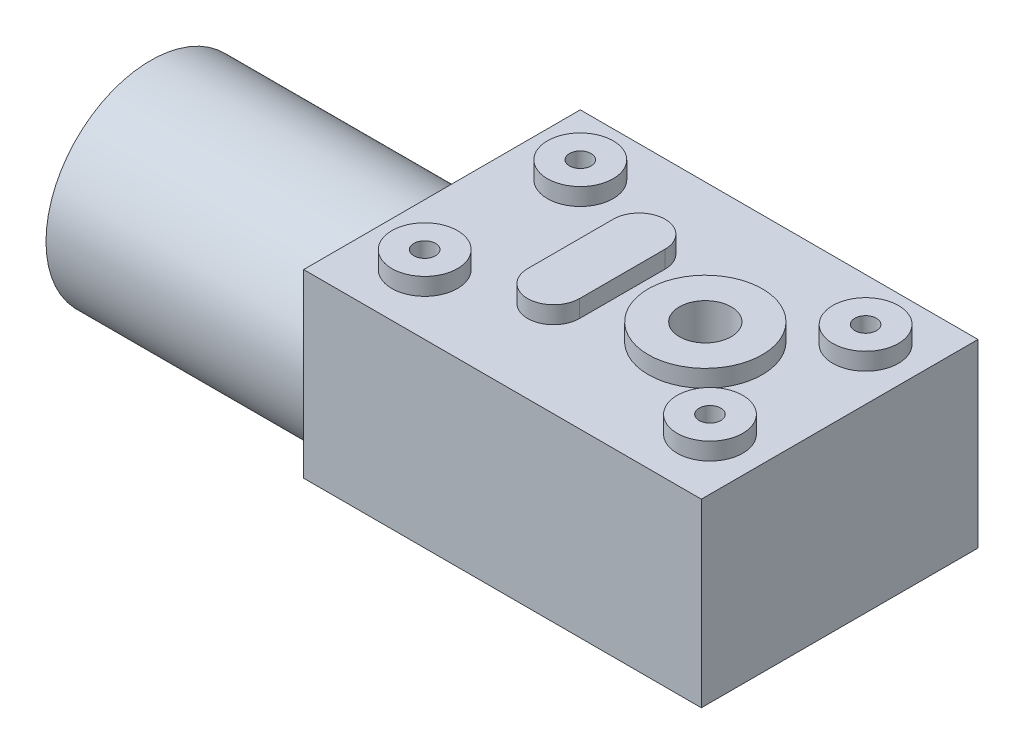
from build123d import *

# Parameters (mm, degrees)
SKETCH1_W                       = 46
SKETCH1_H                       = 32
SKETCH1_R                       = 3
BOSS_EXTRUDE1_DEPTH             = 22.3
SKETCH3_R                       = 3.8
SKETCH3_R_2                     = 6.6
BOSS_EXTRUDE3_DEPTH             = 2
SKETCH4_R                       = 3
CUT_EXTRUDE1_DEPTH              = 3
SKETCH2_R                       = 12.1
BOSS_EXTRUDE2_DEPTH             = 30.8
CHAMFER1_SIZE                   = 1.4
CHAMFER1_SIZE2                  = 5.224871131
CHAMFER1_PART_2_SIZE            = 1.4
CHAMFER1_PART_2_SIZE2           = 5.224871131
CHAMFER1_PART_3_SIZE            = 1.4
CHAMFER1_PART_3_SIZE2           = 5.224871131
TAP_DRILL_FOR_M3X0_5_TAP1_D     = 2.5
TAP_DRILL_FOR_M3X0_5_TAP1_DEPTH = 2.6
TAP_DRILL_FOR_M3X0_5_TAP1_TIP   = 0.751075774
SKETCH8_R                       = 11.8
CUT_EXTRUDE2_DEPTH              = 0.8
SKETCH7_R                       = 3.2
BOSS_EXTRUDE5_DEPTH             = 2.7


with BuildPart() as part:
    # Sketch1 → Boss-Extrude1 (new body)
    with BuildSketch(Plane(origin=(0, 0, 0), x_dir=(1, 0, 0), z_dir=(0, 1, 0))):
        Rectangle(SKETCH1_W, SKETCH1_H)
        with Locations((7.460620525, 0)):
            Circle(SKETCH1_R, mode=Mode.SUBTRACT)
    extrude(amount=BOSS_EXTRUDE1_DEPTH)

    # Sketch3 → Boss-Extrude3 (add)
    with BuildSketch(Plane(origin=(0, 22.3, 0), x_dir=(1, 0, 0), z_dir=(0, 1, 0))):
        with Locations((-16, -9)):
            Circle(SKETCH3_R)
        with Locations((7.460620525, 0)):
            Circle(SKETCH3_R_2)
        with Locations((17, -9)):
            Circle(SKETCH3_R)
        with Locations((17, 9)):
            Circle(SKETCH3_R)
        with Locations((-16, 9)):
            Circle(SKETCH3_R)
        with BuildLine():
            Line((-8.139379475, -4.95), (-8.139379475, 4.95))
            ThreePointArc((-8.139379475, 4.95), (-5.139379475, 7.95), (-2.139379475, 4.95))
            Line((-2.139379475, 4.95), (-2.139379475, -4.95))
            ThreePointArc((-2.139379475, -4.95), (-5.139379475, -7.95), (-8.139379475, -4.95))
        make_face()
    extrude(amount=BOSS_EXTRUDE3_DEPTH)

    # Sketch4 → Cut-Extrude1 (cut, through all)
    with BuildSketch(Plane.XZ.offset(-22.3)):
        with Locations((7.460620525, 0)):
            Circle(SKETCH4_R)
    extrude(amount=-CUT_EXTRUDE1_DEPTH, mode=Mode.SUBTRACT)

    # Sketch2 → Boss-Extrude2 (add)
    with BuildSketch(Plane.ZY.offset(23)):
        with Locations((2.9, 9.2)):
            Circle(SKETCH2_R)
    extrude(amount=BOSS_EXTRUDE2_DEPTH)

    # Chamfer1
    chamfer1_edges = [part.edges().sort_by_distance(p)[0] for p in [
        (0, 0, -16),
    ]]
    chamfer1_side = [part.faces().sort_by_distance(p)[0] for p in [
        (0, 11.15, -16),
    ]]
    chamfer(chamfer1_edges, length=CHAMFER1_SIZE, length2=CHAMFER1_SIZE2, reference=chamfer1_side[0])

    # Chamfer1 part 2
    chamfer1_part_2_edges = [part.edges().sort_by_distance(p)[0] for p in [
        (23, 0, 0),
    ]]
    chamfer1_part_2_side = [part.faces().sort_by_distance(p)[0] for p in [
        (23, 11.15, 0),
    ]]
    chamfer(chamfer1_part_2_edges, length=CHAMFER1_PART_2_SIZE, length2=CHAMFER1_PART_2_SIZE2, reference=chamfer1_part_2_side[0])

    # Chamfer1 part 3
    chamfer1_part_3_edges = [part.edges().sort_by_distance(p)[0] for p in [
        (0, 0, 16),
    ]]
    chamfer1_part_3_side = [part.faces().sort_by_distance(p)[0] for p in [
        (0, 11.15, 16),
    ]]
    chamfer(chamfer1_part_3_edges, length=CHAMFER1_PART_3_SIZE, length2=CHAMFER1_PART_3_SIZE2, reference=chamfer1_part_3_side[0])

    # Tap Drill for M3x0.5 Tap1
    with Locations(Plane(origin=(0, 24.3, 0), x_dir=(1, 0, 0), z_dir=(0, 1, 0))):
        with Locations((-16, -9), (-16, 9), (17, 9), (17, -9)):
            Hole(TAP_DRILL_FOR_M3X0_5_TAP1_D / 2, depth=TAP_DRILL_FOR_M3X0_5_TAP1_DEPTH)
            with Locations((0, 0, -(TAP_DRILL_FOR_M3X0_5_TAP1_DEPTH + TAP_DRILL_FOR_M3X0_5_TAP1_TIP / 2))):  # 118° drill point
                Cone(0, TAP_DRILL_FOR_M3X0_5_TAP1_D / 2, TAP_DRILL_FOR_M3X0_5_TAP1_TIP, mode=Mode.SUBTRACT)

    # Sketch8 → Cut-Extrude2 (cut)
    with BuildSketch(Plane.ZY.offset(53.8)):
        with Locations((2.9, 9.2)):
            Circle(SKETCH8_R)
    extrude(amount=-CUT_EXTRUDE2_DEPTH, mode=Mode.SUBTRACT)

    # Sketch7 → Boss-Extrude5 (add)
    with BuildSketch(Plane.ZY.offset(53)):
        with Locations((2.9, 9.2)):
            Circle(SKETCH7_R)
    extrude(amount=BOSS_EXTRUDE5_DEPTH)


solid = part.part
